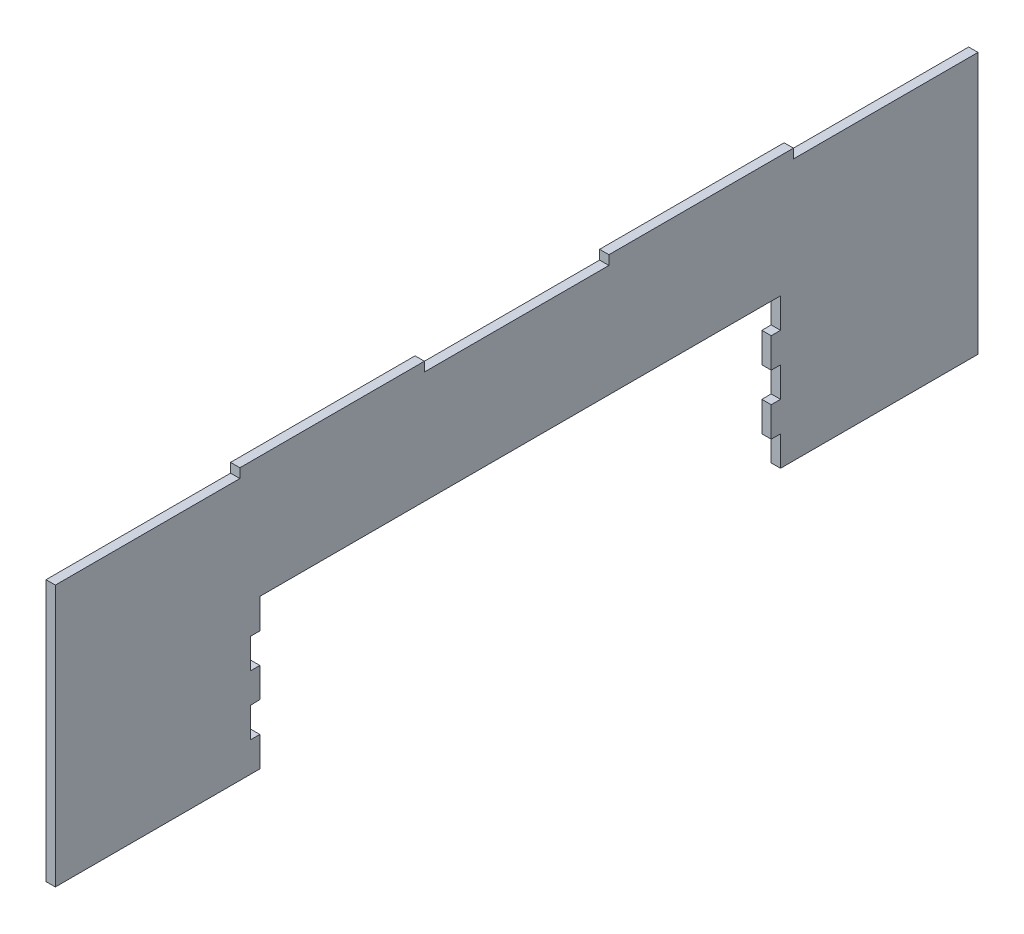
from build123d import *

# Parameters (mm, degrees)
BOSS_EXTRUDE1_DEPTH = 5


with BuildPart() as part:
    # Sketch1 → Boss-Extrude1 (new body)
    with BuildSketch(Plane(origin=(0, 0, 0), x_dir=(0, 0, -1), z_dir=(1, 0, 0))):
        Polygon((-247, 67.5), (-148.2, 67.5), (-148.2, 72.5), (-49.4, 72.5), (-49.4, 67.5), (49.4, 67.5), (49.4, 72.5), (148.2, 72.5), (148.2, 67.5), (247, 67.5), (247, -72.5), (141.262721236, -72.5), (141.262721236, -56.5), (136.262721236, -56.5), (136.262721236, -40.5), (141.262721236, -40.5), (141.262721236, -24.5), (136.262721236, -24.5), (136.262721236, -8.5), (141.262721236, -8.5), (141.262721236, 7.5), (0, 7.5), (-137.5, 7.5), (-137.5, -8.5), (-142.5, -8.5), (-142.5, -24.5), (-137.5, -24.5), (-137.5, -40.359311741), (-142.5, -40.5), (-142.5, -56.5), (-137.5, -56.5), (-137.5, -72.5), (-247, -72.5), align=None)
    extrude(amount=BOSS_EXTRUDE1_DEPTH)


solid = part.part
